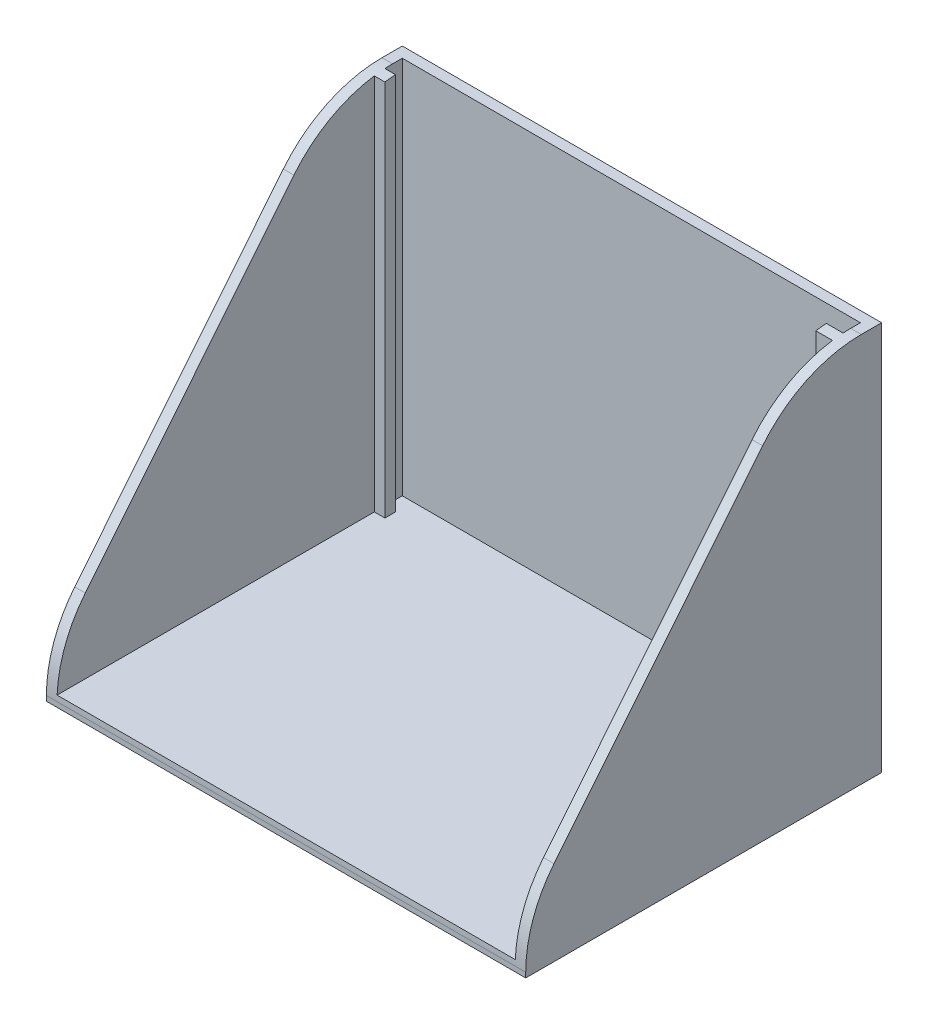
from build123d import *

# Parameters (mm, degrees)
BOSS_EXTRUDE1_DEPTH = 45.5
SKETCH2_W           = 57.548
SKETCH2_H           = 4.628
BOSS_EXTRUDE2_DEPTH = 1.27
BOSS_EXTRUDE3_DEPTH = 38.1
CHAMFER2_SIZE       = 33.02
CHAMFER2_SIZE2      = 40.776304109
FILLET2_R           = 15.24
FILLET3_R           = 15.24


with BuildPart() as part:
    # Sketch1 → Boss-Extrude1 (new body)
    with BuildSketch(Plane.XZ.offset(154.681799526)):
        Polygon((108.516, 1.834), (107.246, 1.834), (107.246, -0.254), (146.442611067, -0.254), (162.254, -0.254), (162.254, 1.834), (160.252914004, 1.834), (160.252914004, 3.104), (163.524, 3.104), (163.524, -1.524), (105.976, -1.524), (105.976, 3.104), (108.516, 3.104), align=None)
    extrude(amount=-BOSS_EXTRUDE1_DEPTH)

    # Sketch2 → Boss-Extrude2 (add)
    with BuildSketch(Plane.XZ.offset(154.681799526)):
        with Locations((134.75, 0.79)):
            Rectangle(SKETCH2_W, SKETCH2_H)
    extrude(amount=BOSS_EXTRUDE2_DEPTH)

    # Sketch8 → Boss-Extrude3 (add)
    with BuildSketch(Plane.XY.offset(3.104)):
        Polygon((105.976, -109.181799526), (107.246, -109.181799526), (107.246, -154.681799526), (162.254, -154.681799526), (162.254, -109.181799526), (163.524, -109.181799526), (163.524, -155.951799526), (105.976, -155.951799526), align=None)
    extrude(amount=BOSS_EXTRUDE3_DEPTH)

    # Chamfer2
    chamfer2_edges = [part.edges().sort_by_distance(p)[0] for p in [
        (162.889, -109.181799526, 41.204),
        (106.611, -109.181799526, 41.204),
    ]]
    chamfer2_side = [part.faces().sort_by_distance(p)[0] for p in [
        (107.881, -109.181799526, 2.550760371),
    ]]
    chamfer(chamfer2_edges, length=CHAMFER2_SIZE, length2=CHAMFER2_SIZE2, reference=chamfer2_side[0])

    # Fillet2
    fillet2_edges = [part.edges().sort_by_distance(p)[0] for p in [
        (162.889, -109.181799526, 8.184),
        (106.611, -109.181799526, 8.184),
    ]]
    fillet(fillet2_edges, radius=FILLET2_R)

    # Fillet3
    fillet3_edges = [part.edges().sort_by_distance(p)[0] for p in [
        (106.611, -149.958103635, 41.204),
    ]]
    fillet(fillet3_edges, radius=FILLET3_R)


solid = part.part
